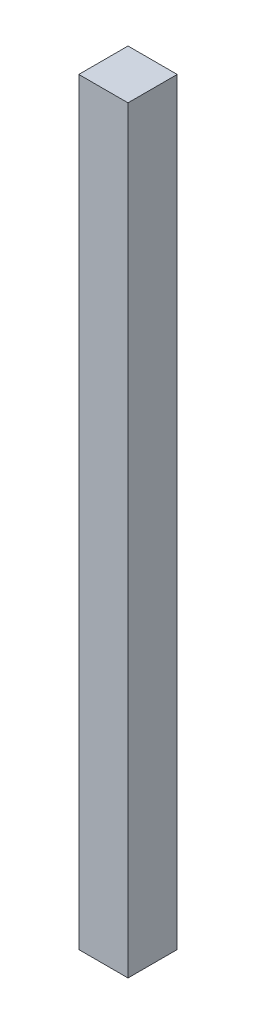
from build123d import *

# Parameters (mm, degrees)
SKETCH1_W           = 50
SKETCH1_H           = 50
BOSS_EXTRUDE1_DEPTH = 770


with BuildPart() as part:
    # Sketch1 → Boss-Extrude1 (new body)
    with BuildSketch(Plane(origin=(0, 0, 0), x_dir=(1, 0, 0), z_dir=(0, 1, 0))):
        Rectangle(SKETCH1_W, SKETCH1_H)
    extrude(amount=BOSS_EXTRUDE1_DEPTH)


solid = part.part
